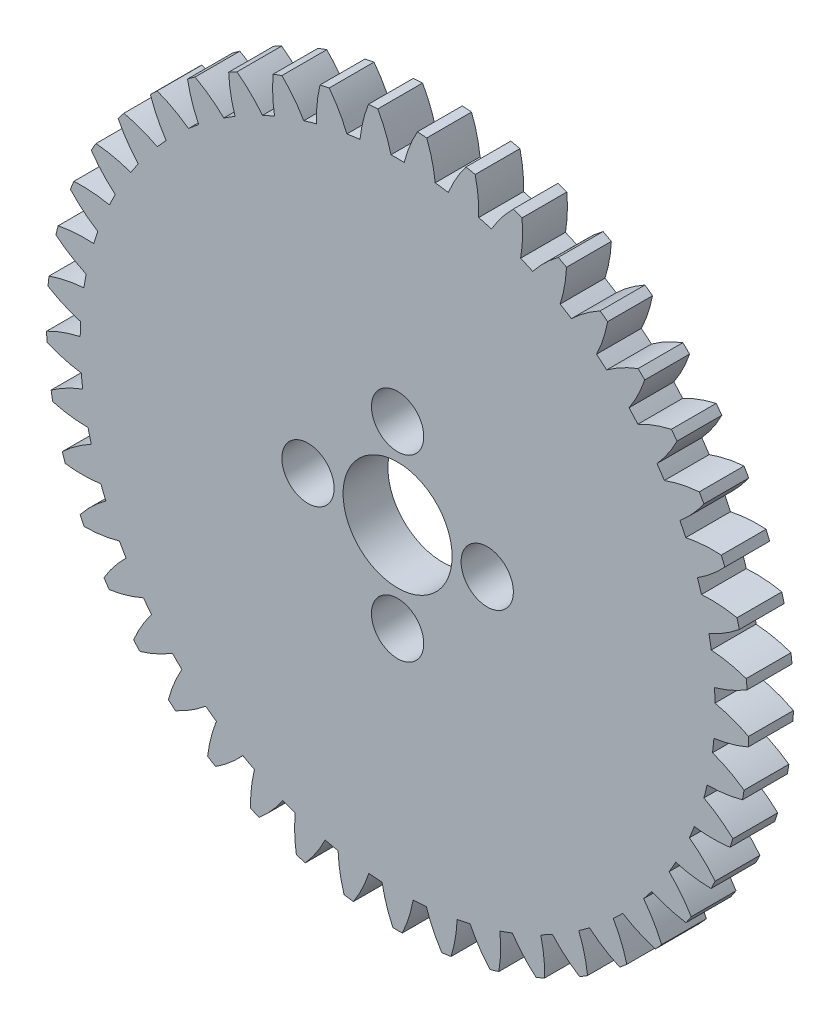
from build123d import *

# Parameters (mm, degrees)
BOSS_EXTRUDE1_DEPTH = 3
SKETCH2_R           = 3.65
CUT_EXTRUDE1_DEPTH  = 3
SKETCH3_R           = 1.75
CUT_EXTRUDE2_DEPTH  = 3
CIRPATTERN1_COUNT   = 4


with BuildPart() as part:
    # Model → Boss-Extrude1 (new body)
    with BuildSketch(Plane.XY):
        with BuildLine():
            ThreePointArc((32.442634493, 93.418604181), (32.407825649, 93.107382285), (32.377167165, 92.795724168))
            ThreePointArc((32.377167165, 92.795724168), (33.438114337, 92.242398237), (34.563087863, 91.834705887))
            ThreePointArc((34.563087863, 91.834705887), (34.543034507, 91.392542803), (34.532195277, 90.950057955))
            ThreePointArc((34.532195277, 90.950057955), (33.381522949, 90.62183291), (32.284562125, 90.143862787))
            ThreePointArc((32.284562125, 90.143862787), (32.293405755, 89.830825225), (32.306420064, 89.517933307))
            ThreePointArc((32.306420064, 89.517933307), (33.434050257, 89.117647614), (34.604815427, 88.870488953))
            ThreePointArc((34.604815427, 88.870488953), (34.646494435, 88.429838082), (34.697342681, 87.990150937))
            ThreePointArc((34.697342681, 87.990150937), (33.603548714, 87.504977519), (32.583784022, 86.878991529))
            ThreePointArc((32.583784022, 86.878991529), (32.636107994, 86.570231223), (32.692541788, 86.262195589))
            ThreePointArc((32.692541788, 86.262195589), (33.864906962, 86.02274124), (35.058676163, 85.940926928))
            ThreePointArc((35.058676163, 85.940926928), (35.161276302, 85.510365038), (35.272822319, 85.082033606))
            ThreePointArc((35.272822319, 85.082033606), (34.25719617, 84.449355164), (33.334476169, 83.687537413))
            ThreePointArc((33.334476169, 83.687537413), (33.429262057, 83.38906403), (33.528016915, 83.091880244))
            ThreePointArc((33.528016915, 83.091880244), (34.722298316, 83.017917945), (35.915836189, 83.103040406))
            ThreePointArc((35.915836189, 83.103040406), (36.077360464, 82.690947894), (36.247433137, 82.282309159))
            ThreePointArc((36.247433137, 82.282309159), (35.329742812, 81.51444006), (34.522027198, 80.631618462))
            ThreePointArc((34.522027198, 80.631618462), (34.657430102, 80.349241448), (34.796583874, 80.068693855))
            ThreePointArc((34.796583874, 80.068693855), (35.989536173, 80.161663197), (37.15961186, 80.412065619))
            ThreePointArc((37.15961186, 80.412065619), (37.376916385, 80.026463398), (37.602205442, 79.645471048))
            ThreePointArc((37.602205442, 79.645471048), (36.80031274, 78.75735699), (36.123322778, 77.770714665))
            ThreePointArc((36.123322778, 77.770714665), (36.296707235, 77.509930166), (36.47355145, 77.251479304))
            ThreePointArc((36.47355145, 77.251479304), (37.641955188, 77.509570746), (38.765794498, 77.920379331))
            ThreePointArc((38.765794498, 77.920379331), (39.034649687, 77.568772709), (39.310770133, 77.222842327))
            ThreePointArc((39.310770133, 77.222842327), (38.640282982, 76.23176944), (38.107195512, 75.160510257))
            ThreePointArc((38.107195512, 75.160510257), (38.315186791, 74.926394149), (38.526279379, 74.69507047))
            ThreePointArc((38.526279379, 74.69507047), (39.647392905, 75.113260556), (40.703121583, 75.676479381))
            ThreePointArc((40.703121583, 75.676479381), (41.018294476, 75.365711981), (41.339871941, 75.061576708))
            ThreePointArc((41.339871941, 75.061576708), (40.813840613, 73.986835098), (40.435031575, 72.851809901))
            ThreePointArc((40.435031575, 72.851809901), (40.673581362, 72.648918985), (40.914813645, 72.449224943))
            ThreePointArc((40.914813645, 72.449224943), (41.966815761, 73.019374077), (42.933885249, 73.724040729))
            ThreePointArc((42.933885249, 73.724040729), (43.289241364, 73.460161285), (43.650016708, 73.203740769))
            ThreePointArc((43.650016708, 73.203740769), (43.278679803, 72.066249059), (43.061522286, 70.88954982))
            ThreePointArc((43.061522286, 70.88954982), (43.325987481, 70.721833138), (43.592664146, 70.55765555))
            ThreePointArc((43.592664146, 70.55765555), (44.555078827, 71.268666429), (45.414666218, 72.101065373))
            ThreePointArc((45.414666218, 72.101065373), (45.803288952, 71.889209997), (46.196240094, 71.685495172))
            ThreePointArc((46.196240094, 71.685495172), (45.986825263, 70.507393345), (45.935545989, 69.311923177))
            ThreePointArc((45.935545989, 69.311923177), (46.220779078, 69.182645144), (46.507709569, 69.057179539))
            ThreePointArc((46.507709569, 69.057179539), (47.361804507, 69.895213144), (48.09717891, 70.839142682))
            ThreePointArc((48.09717891, 70.839142682), (48.511504164, 70.683434899), (48.928982756, 70.536390841))
            ThreePointArc((48.928982756, 70.536390841), (48.88556602, 69.340609308), (49.001163084, 68.149636678))
            ThreePointArc((49.001163084, 68.149636678), (49.301612328, 68.061313543), (49.603211868, 67.977001967))
            ThreePointArc((49.603211868, 67.977001967), (50.332363078, 68.925746928), (50.929211268, 69.962834545))
            ThreePointArc((50.929211268, 69.962834545), (51.361174672, 69.86630503), (51.795054968, 69.778793785))
            ThreePointArc((51.795054968, 69.778793785), (51.918481385, 68.588607074), (52.19870482, 67.42531291))
            ThreePointArc((52.19870482, 67.42531291), (52.508522317, 67.379663782), (52.818920615, 67.338147264))
            ThreePointArc((52.818920615, 67.338147264), (53.408935997, 68.379137339), (53.855641001, 69.489197304))
            ThreePointArc((53.855641001, 69.489197304), (54.296834879, 69.453724894), (54.738671894, 69.427449769))
            ThreePointArc((54.738671894, 69.427449769), (55.026539108, 68.26602351), (55.465934684, 67.153050009))
            ThreePointArc((55.465934684, 67.153050009), (55.77909019, 67.150963398), (56.092245695, 67.153050009))
            ThreePointArc((56.092245695, 67.153050009), (56.531641271, 68.26602351), (56.819508486, 69.427449769))
            ThreePointArc((56.819508486, 69.427449769), (57.2613455, 69.453724894), (57.702539378, 69.489197304))
            ThreePointArc((57.702539378, 69.489197304), (58.149244383, 68.379137339), (58.739259765, 67.338147264))
            ThreePointArc((58.739259765, 67.338147264), (59.049658062, 67.379663782), (59.35947556, 67.42531291))
            ThreePointArc((59.35947556, 67.42531291), (59.639698995, 68.588607074), (59.763125412, 69.778793785))
            ThreePointArc((59.763125412, 69.778793785), (60.197005708, 69.86630503), (60.628969112, 69.962834545))
            ThreePointArc((60.628969112, 69.962834545), (61.225817302, 68.925746928), (61.954968511, 67.977001967))
            ThreePointArc((61.954968511, 67.977001967), (62.256568052, 68.061313543), (62.557017296, 68.149636678))
            ThreePointArc((62.557017296, 68.149636678), (62.672614359, 69.340609308), (62.629197623, 70.536390841))
            ThreePointArc((62.629197623, 70.536390841), (63.046676215, 70.683434899), (63.461001469, 70.839142682))
            ThreePointArc((63.461001469, 70.839142682), (64.196375873, 69.895213143), (65.050470811, 69.057179538))
            ThreePointArc((65.050470811, 69.057179538), (65.337401302, 69.182645143), (65.622634391, 69.311923176))
            ThreePointArc((65.622634391, 69.311923176), (65.571355117, 70.507393345), (65.361940286, 71.685495172))
            ThreePointArc((65.361940286, 71.685495172), (65.754891427, 71.889209997), (66.143514162, 72.101065373))
            ThreePointArc((66.143514162, 72.101065373), (67.003101553, 71.268666428), (67.965516234, 70.55765555))
            ThreePointArc((67.965516234, 70.55765555), (68.232192899, 70.721833138), (68.496658094, 70.88954982))
            ThreePointArc((68.496658094, 70.88954982), (68.279500577, 72.066249059), (67.908163672, 73.203740769))
            ThreePointArc((67.908163672, 73.203740769), (68.268939016, 73.460161284), (68.624295131, 73.724040729))
            ThreePointArc((68.624295131, 73.724040729), (69.591364619, 73.019374077), (70.643366735, 72.449224943))
            ThreePointArc((70.643366735, 72.449224943), (70.884599017, 72.648918985), (71.123148805, 72.8518099))
            ThreePointArc((71.123148805, 72.8518099), (70.744339767, 73.986835098), (70.218308439, 75.061576708))
            ThreePointArc((70.218308439, 75.061576708), (70.539885904, 75.36571198), (70.855058797, 75.676479381))
            ThreePointArc((70.855058797, 75.676479381), (71.910787474, 75.113260555), (73.031901001, 74.69507047))
            ThreePointArc((73.031901001, 74.69507047), (73.242993589, 74.926394148), (73.450984868, 75.160510257))
            ThreePointArc((73.450984868, 75.160510257), (72.917897397, 76.23176944), (72.247410247, 77.222842327))
            ThreePointArc((72.247410247, 77.222842327), (72.523530693, 77.568772709), (72.792385882, 77.920379331))
            ThreePointArc((72.792385882, 77.920379331), (73.916225192, 77.509570746), (75.084628929, 77.251479304))
            ThreePointArc((75.084628929, 77.251479304), (75.261473145, 77.509930166), (75.434857602, 77.770714665))
            ThreePointArc((75.434857602, 77.770714665), (74.75786764, 78.75735699), (73.955974938, 79.645471048))
            ThreePointArc((73.955974938, 79.645471048), (74.181263995, 80.026463398), (74.39856852, 80.412065619))
            ThreePointArc((74.39856852, 80.412065619), (75.568644207, 80.161663197), (76.761596506, 80.068693855))
            ThreePointArc((76.761596506, 80.068693855), (76.900750278, 80.349241448), (77.036153182, 80.631618462))
            ThreePointArc((77.036153182, 80.631618462), (76.228437568, 81.51444006), (75.310747243, 82.282309159))
            ThreePointArc((75.310747243, 82.282309159), (75.480819916, 82.690947894), (75.642344191, 83.103040406))
            ThreePointArc((75.642344191, 83.103040406), (76.835882063, 83.017917945), (78.030163465, 83.091880244))
            ThreePointArc((78.030163465, 83.091880244), (78.128918323, 83.38906403), (78.223704211, 83.687537413))
            ThreePointArc((78.223704211, 83.687537413), (77.30098421, 84.449355164), (76.28535806, 85.082033606))
            ThreePointArc((76.28535806, 85.082033606), (76.396904077, 85.510365038), (76.499504217, 85.940926928))
            ThreePointArc((76.499504217, 85.940926928), (77.693273418, 86.02274124), (78.865638592, 86.262195589))
            ThreePointArc((78.865638592, 86.262195589), (78.922072386, 86.570231223), (78.974396358, 86.878991529))
            ThreePointArc((78.974396358, 86.878991529), (77.954631666, 87.504977519), (76.860837699, 87.990150937))
            ThreePointArc((76.860837699, 87.990150937), (76.911685945, 88.429838082), (76.953364953, 88.870488953))
            ThreePointArc((76.953364953, 88.870488953), (78.124130123, 89.117647614), (79.251760315, 89.517933307))
            ThreePointArc((79.251760315, 89.517933307), (79.264774625, 89.830825225), (79.273618254, 90.143862787))
            ThreePointArc((79.273618254, 90.143862787), (78.176657431, 90.62183291), (77.025985103, 90.950057955))
            ThreePointArc((77.025985103, 90.950057955), (77.015145873, 91.392542803), (76.995092516, 91.834705887))
            ThreePointArc((76.995092516, 91.834705887), (78.120066043, 92.242398237), (79.181013214, 92.795724168))
            ThreePointArc((79.181013214, 92.795724168), (79.150354731, 93.107382285), (79.115545887, 93.418604181))
            ThreePointArc((79.115545887, 93.418604181), (77.962740026, 93.739255293), (76.777585865, 93.904143438))
            ThreePointArc((76.777585865, 93.904143438), (76.705270134, 94.340813525), (76.623874727, 94.77588262))
            ThreePointArc((76.623874727, 94.77588262), (77.68116028, 95.33617339), (78.654774301, 96.031769699))
            ThreePointArc((78.654774301, 96.031769699), (78.581039757, 96.336127944), (78.503255954, 96.639476596))
            ThreePointArc((78.503255954, 96.639476596), (77.317043112, 96.796567587), (76.120474794, 96.794909472))
            ThreePointArc((76.120474794, 96.794909472), (75.988090105, 97.217265511), (75.846936918, 97.636772493))
            ThreePointArc((75.846936918, 97.636772493), (76.815955636, 98.33875626), (77.683286217, 99.163083956))
            ThreePointArc((77.683286217, 99.163083956), (77.567910772, 99.454218343), (77.448665983, 99.743789414))
            ThreePointArc((77.448665983, 99.743789414), (76.252134442, 99.734262685), (75.06744181, 99.566090585))
            ThreePointArc((75.06744181, 99.566090585), (74.87756488, 99.965911896), (74.679401298, 100.361691538))
            ThreePointArc((74.679401298, 100.361691538), (75.541292335, 101.191704987), (76.285457873, 102.128719469))
            ThreePointArc((76.285457873, 102.128719469), (76.130687179, 102.400963398), (75.972302368, 102.671120715))
            ThreePointArc((75.972302368, 102.671120715), (74.788741254, 102.495161696), (73.638983002, 102.163748887))
            ThreePointArc((73.638983002, 102.163748887), (73.395309569, 102.533253404), (73.143992622, 102.897602305))
            ThreePointArc((73.143992622, 102.897602305), (73.881980249, 103.839490169), (74.488496408, 104.870953516))
            ThreePointArc((74.488496408, 104.870953516), (74.2973429, 105.119008068), (74.102900847, 105.364493328))
            ThreePointArc((74.102900847, 105.364493328), (72.955346831, 105.025526859), (71.862901696, 104.537323916))
            ThreePointArc((71.862901696, 104.537323916), (71.570174586, 104.869319652), (71.270595872, 105.195146176))
            ThreePointArc((71.270595872, 105.195146176), (71.870316, 106.230575679), (72.327377633, 107.33641163))
            ThreePointArc((72.327377633, 107.33641163), (72.103561896, 107.555448706), (71.876847195, 107.771483817))
            ThreePointArc((71.876847195, 107.771483817), (70.78763611, 107.276107495), (69.773767294, 106.640616732))
            ThreePointArc((69.773767294, 106.640616732), (69.437684108, 106.92864177), (69.095674586, 107.209604074))
            ThreePointArc((69.095674586, 107.209604074), (69.545454343, 108.318421758), (69.844165265, 109.477106474))
            ThreePointArc((69.844165265, 109.477106474), (69.592043619, 109.662862766), (69.337469014, 109.84524285))
            ThreePointArc((69.337469014, 109.84524285), (68.327801115, 109.203098612), (67.41224242, 108.432689135))
            ThreePointArc((67.41224242, 108.432689135), (67.039344636, 108.671137393), (66.661561131, 108.901766865))
            ThreePointArc((66.661561131, 108.901766865), (66.952646068, 110.062390856), (67.087192211, 111.251371857))
            ThreePointArc((67.087192211, 111.251371857), (66.811671915, 111.40023183), (66.534192411, 111.545407066))
            ThreePointArc((66.534192411, 111.545407066), (65.623719736, 110.76899352), (64.824291471, 109.878660472))
            ThreePointArc((64.824291471, 109.878660472), (64.421837119, 110.062890827), (64.015632758, 110.238698528))
            ThreePointArc((64.015632758, 110.238698528), (64.142357237, 111.428538598), (64.110119813, 112.624673722))
            ThreePointArc((64.110119813, 112.624673722), (63.816563558, 112.733739986), (63.521579977, 112.838884704))
            ThreePointArc((63.521579977, 112.838884704), (62.72802384, 111.943313856), (62.060285968, 110.950386557))
            ThreePointArc((62.060285968, 110.950386557), (61.636108364, 111.076813175), (61.209389454, 111.194377206))
            ThreePointArc((61.209389454, 111.194377206), (61.169286926, 112.390274474), (60.9708934, 113.570282311))
            ThreePointArc((60.9708934, 113.570282311), (60.665014924, 113.637432015), (60.358268787, 113.700499692))
            ThreePointArc((60.358268787, 113.700499692), (59.697074856, 112.703202809), (59.174024134, 111.62700746))
            ThreePointArc((59.174024134, 111.62700746), (58.736379412, 111.693169591), (58.29745155, 111.750201703))
            ThreePointArc((58.29745155, 111.750201703), (58.091302566, 112.928879387), (57.730614443, 114.069792427))
            ThreePointArc((57.730614443, 114.069792427), (57.418367323, 114.093718579), (57.105829094, 114.113481675))
            ThreePointArc((57.105829094, 114.113481675), (56.589866756, 113.033870007), (56.221683772, 111.895353526))
            ThreePointArc((56.221683772, 111.895353526), (55.77909019, 111.899963398), (55.336496608, 111.895353526))
            ThreePointArc((55.336496608, 111.895353526), (54.968313623, 113.033870007), (54.452351286, 114.113481674))
            ThreePointArc((54.452351286, 114.113481674), (54.139813057, 114.093718579), (53.827565937, 114.069792427))
            ThreePointArc((53.827565937, 114.069792427), (53.466877813, 112.928879387), (53.260728829, 111.750201703))
            ThreePointArc((53.260728829, 111.750201703), (52.821800968, 111.693169591), (52.384156246, 111.62700746))
            ThreePointArc((52.384156246, 111.62700746), (51.861105524, 112.703202809), (51.199911593, 113.700499692))
            ThreePointArc((51.199911593, 113.700499692), (50.893165456, 113.637432015), (50.58728698, 113.570282311))
            ThreePointArc((50.58728698, 113.570282311), (50.388893454, 112.390274474), (50.348790926, 111.194377206))
            ThreePointArc((50.348790926, 111.194377206), (49.922072016, 111.076813175), (49.497894412, 110.950386557))
            ThreePointArc((49.497894412, 110.950386557), (48.830156539, 111.943313856), (48.036600402, 112.838884704))
            ThreePointArc((48.036600402, 112.838884704), (47.741616822, 112.733739986), (47.448060567, 112.624673722))
            ThreePointArc((47.448060567, 112.624673722), (47.415823143, 111.428538598), (47.542547621, 110.238698528))
            ThreePointArc((47.542547621, 110.238698528), (47.136343261, 110.062890827), (46.733888908, 109.878660472))
            ThreePointArc((46.733888908, 109.878660472), (45.934460644, 110.76899352), (45.023987969, 111.545407066))
            ThreePointArc((45.023987969, 111.545407066), (44.746508464, 111.40023183), (44.470988169, 111.251371857))
            ThreePointArc((44.470988169, 111.251371857), (44.605534312, 110.062390856), (44.896619248, 108.901766866))
            ThreePointArc((44.896619248, 108.901766866), (44.518835744, 108.671137393), (44.145937959, 108.432689135))
            ThreePointArc((44.145937959, 108.432689135), (43.230379264, 109.203098612), (42.220711366, 109.84524285))
            ThreePointArc((42.220711366, 109.84524285), (41.966136761, 109.662862766), (41.714015114, 109.477106474))
            ThreePointArc((41.714015114, 109.477106474), (42.012726036, 108.318421758), (42.462505794, 107.209604074))
            ThreePointArc((42.462505794, 107.209604074), (42.120496272, 106.92864177), (41.784413086, 106.640616733))
            ThreePointArc((41.784413086, 106.640616733), (40.770544269, 107.276107495), (39.681333185, 107.771483817))
            ThreePointArc((39.681333185, 107.771483817), (39.454618484, 107.555448706), (39.230802747, 107.33641163))
            ThreePointArc((39.230802747, 107.33641163), (39.68786438, 106.230575679), (40.287584507, 105.195146176))
            ThreePointArc((40.287584507, 105.195146176), (39.988005793, 104.869319652), (39.695278684, 104.537323916))
            ThreePointArc((39.695278684, 104.537323916), (38.602833549, 105.025526859), (37.455279533, 105.364493328))
            ThreePointArc((37.455279533, 105.364493328), (37.26083748, 105.119008068), (37.069683971, 104.870953516))
            ThreePointArc((37.069683971, 104.870953516), (37.67620013, 103.839490169), (38.414187758, 102.897602305))
            ThreePointArc((38.414187758, 102.897602305), (38.162870811, 102.533253404), (37.919197377, 102.163748887))
            ThreePointArc((37.919197377, 102.163748887), (36.769439126, 102.495161696), (35.585878012, 102.671120715))
            ThreePointArc((35.585878012, 102.671120715), (35.427493201, 102.400963398), (35.272722506, 102.128719469))
            ThreePointArc((35.272722506, 102.128719469), (36.016888044, 101.191704987), (36.878779081, 100.361691538))
            ThreePointArc((36.878779081, 100.361691538), (36.6806155, 99.965911896), (36.490738569, 99.566090585))
            ThreePointArc((36.490738569, 99.566090585), (35.306045938, 99.734262686), (34.109514397, 99.743789414))
            ThreePointArc((34.109514397, 99.743789414), (33.990269607, 99.454218343), (33.874894162, 99.163083956))
            ThreePointArc((33.874894162, 99.163083956), (34.742224744, 98.33875626), (35.711243462, 97.636772493))
            ThreePointArc((35.711243462, 97.636772493), (35.570090275, 97.217265511), (35.437705585, 96.794909472))
            ThreePointArc((35.437705585, 96.794909472), (34.241137268, 96.796567587), (33.054924426, 96.639476596))
            ThreePointArc((33.054924426, 96.639476596), (32.977140622, 96.336127944), (32.903406079, 96.031769699))
            ThreePointArc((32.903406079, 96.031769699), (33.8770201, 95.33617339), (34.934305652, 94.77588262))
            ThreePointArc((34.934305652, 94.77588262), (34.852910246, 94.340813525), (34.780594515, 93.904143438))
            ThreePointArc((34.780594515, 93.904143438), (33.595440353, 93.739255293), (32.442634493, 93.418604181))
        make_face()
    extrude(amount=BOSS_EXTRUDE1_DEPTH)

    # Sketch2 → Cut-Extrude1 (cut)
    with BuildSketch(Plane.XY.offset(3)):
        with Locations((55.779090189, 90.650963398)):
            Circle(SKETCH2_R)
    extrude(amount=-CUT_EXTRUDE1_DEPTH, mode=Mode.SUBTRACT)

    # Sketch3 → Cut-Extrude2 (cut)
    with BuildSketch(Plane.XY.offset(3)):
        with Locations((61.779090189, 90.650963398)):
            Circle(SKETCH3_R)
    cut_extrude2 = extrude(amount=-CUT_EXTRUDE2_DEPTH, mode=Mode.SUBTRACT)

    # CirPattern1: Cut-Extrude2 ×4 about axis
    cirpattern1_axis = Axis((55.779090189, 90.650963398, 0), (0, 0, 1))
    for i in range(1, CIRPATTERN1_COUNT):
        add(cut_extrude2.rotate(cirpattern1_axis, i * 360 / CIRPATTERN1_COUNT), mode=Mode.SUBTRACT)


solid = part.part
